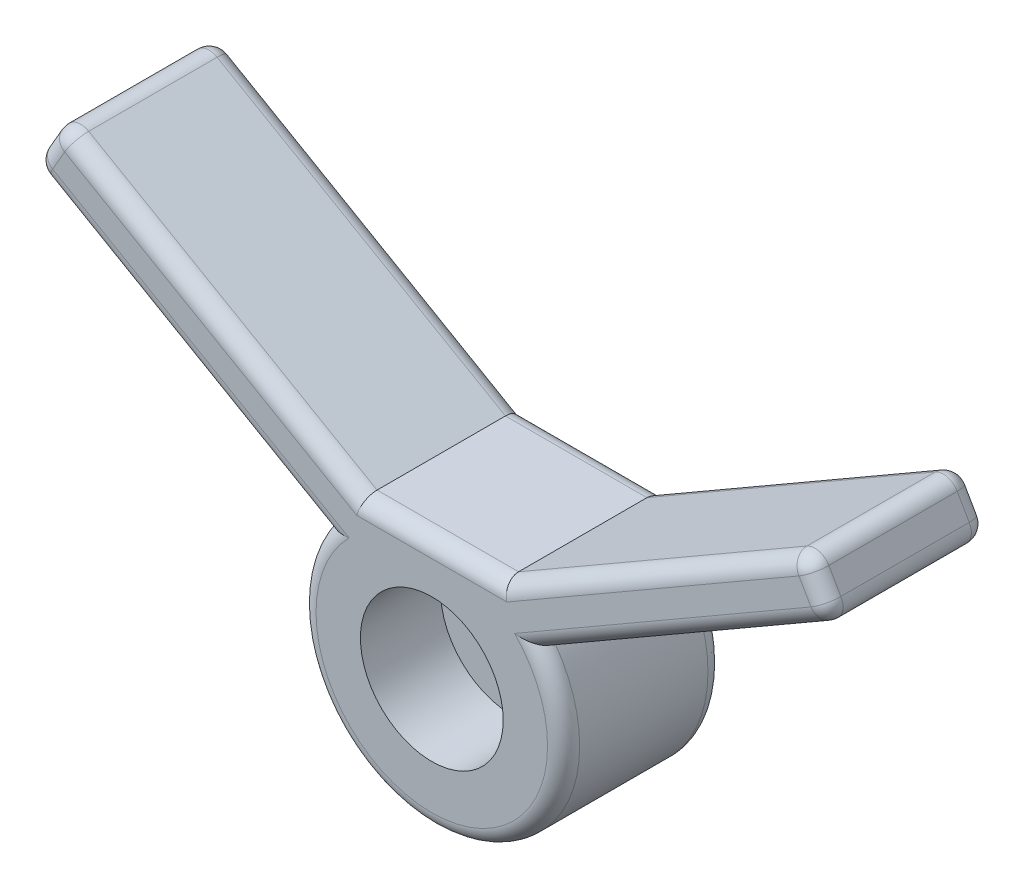
from build123d import *

# Parameters (mm, degrees)
SKETCH2_R           = 3.96875
BOSS_EXTRUDE1_DEPTH = 25.4
FILLET3_R           = 2.54
SKETCH3_R           = 11.303
CUT_EXTRUDE1_DEPTH  = 12.7


with BuildPart() as part:
    # Sketch2 → Boss-Extrude1 (new body)
    with BuildSketch(Plane.XY):
        with BuildLine():
            Line((16.984572795, 2.473699256), (63.5, 29.329393675))
            Line((63.5, 29.329393675), (59.055, 37.028359514))
            Line((59.055, 37.028359514), (11.202045256, 9.400443212))
            Line((11.202045256, 9.400443212), (-11.202045256, 9.400443212))
            Line((-11.202045256, 9.400443212), (-59.055, 37.028359514))
            Line((-59.055, 37.028359514), (-63.5, 29.329393675))
            Line((-63.5, 29.329393675), (-16.984572795, 2.473699256))
            ThreePointArc((-16.984572795, 2.473699256), (0, -30.51697278), (16.984572795, 2.473699256))
        make_face()
        with Locations((0, -9.649556788)):
            Circle(SKETCH2_R, mode=Mode.SUBTRACT)
    extrude(amount=BOSS_EXTRUDE1_DEPTH)

    # Fillet3
    fillet3_edges = [part.edges().sort_by_distance(p)[0] for p in [
        (61.2775, 33.178876595, 0),
        (40.242286397, 15.901546466, 0),
        (0, -30.51697278, 0),
        (-40.242286397, 15.901546466, 0),
        (40.242286397, 15.901546466, 25.4),
        (-63.5, 29.329393675, 12.7),
        (-59.055, 37.028359514, 12.7),
        (59.055, 37.028359514, 12.7),
        (63.5, 29.329393675, 12.7),
        (61.2775, 33.178876595, 25.4),
        (35.128522628, 23.214401363, 25.4),
        (0, 9.400443212, 25.4),
        (-35.128522628, 23.214401363, 25.4),
        (-61.2775, 33.178876595, 25.4),
        (-40.242286397, 15.901546466, 25.4),
        (-61.2775, 33.178876595, 0),
        (0, -30.51697278, 25.4),
        (-35.128522628, 23.214401363, 0),
        (0, 9.400443212, 0),
        (35.128522628, 23.214401363, 0),
    ]]
    fillet(fillet3_edges, radius=FILLET3_R)

    # Sketch3 → Cut-Extrude1 (cut)
    with BuildSketch(Plane.XY.offset(25.4)):
        with Locations((0, -9.649556788)):
            Circle(SKETCH3_R)
    extrude(amount=-CUT_EXTRUDE1_DEPTH, mode=Mode.SUBTRACT)


solid = part.part
